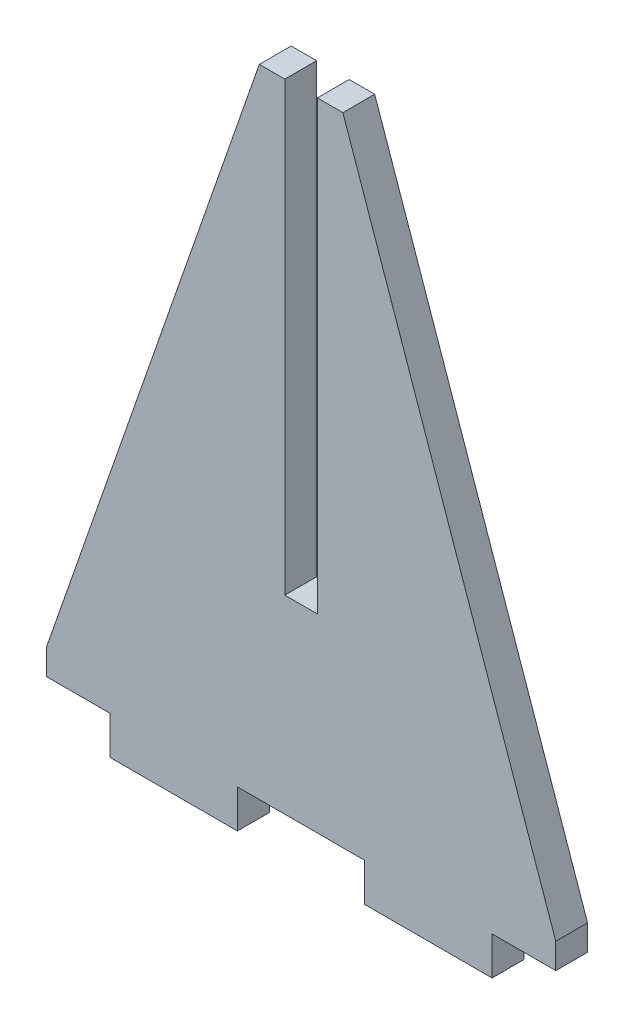
from build123d import *

# Parameters (mm, degrees)
BOSS_EXTRUDE1_DEPTH = 3.175


with BuildPart() as part:
    # Sketch1 → Boss-Extrude1 (new body)
    with BuildSketch(Plane.XY):
        Polygon((-1.6256, 18.923), (-1.6256, 63.5), (-4.1656, 63.5), (-25.4, 2.54), (-25.4, 0), (-19.05, 0), (-19.05, -3.81), (-6.35, -3.81), (-6.35, 0), (0, 0), (6.35, 0), (6.35, -3.81), (19.05, -3.81), (19.05, 0), (25.4, 0), (25.4, 2.54), (4.1656, 63.5), (1.6256, 63.5), (1.6256, 18.923), align=None)
    extrude(amount=BOSS_EXTRUDE1_DEPTH)


solid = part.part
